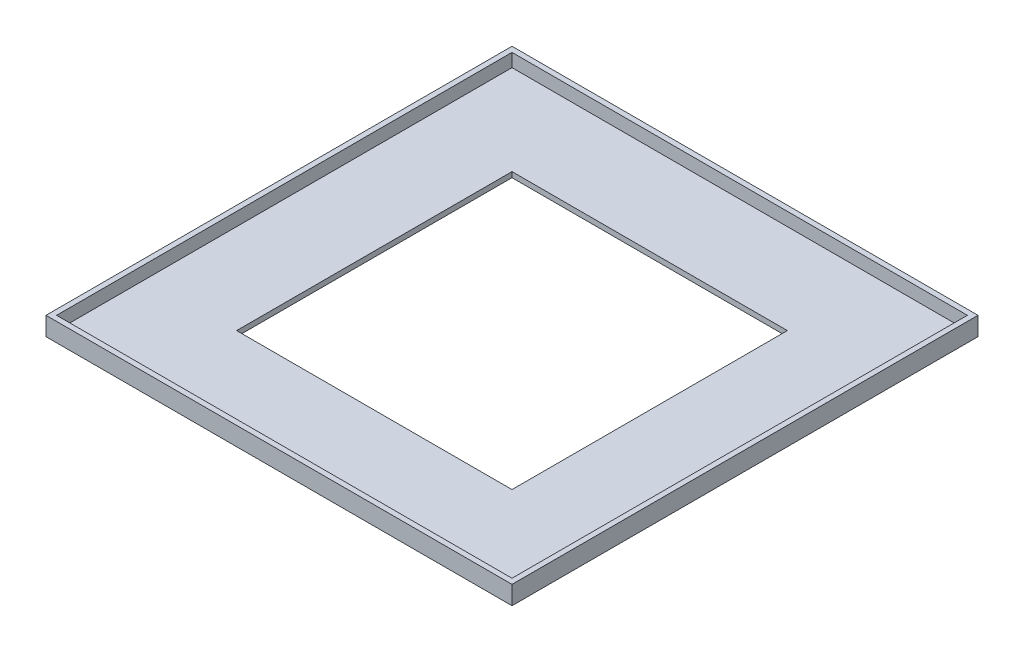
from build123d import *

# Parameters (mm, degrees)
SKETCH1_W           = 88
SKETCH1_H           = 88
BOSS_EXTRUDE1_DEPTH = 3.5
SKETCH2_W           = 86
SKETCH2_H           = 86
CUT_EXTRUDE1_DEPTH  = 2.5
SKETCH3_W           = 52
SKETCH3_H           = 52
CUT_EXTRUDE2_DEPTH  = 2


with BuildPart() as part:
    # Sketch1 → Boss-Extrude1 (new body)
    with BuildSketch(Plane(origin=(0, 0, 0), x_dir=(1, 0, 0), z_dir=(0, 1, 0))):
        Rectangle(SKETCH1_W, SKETCH1_H)
    extrude(amount=BOSS_EXTRUDE1_DEPTH)

    # Sketch2 → Cut-Extrude1 (cut)
    with BuildSketch(Plane(origin=(0, 3.5, 0), x_dir=(1, 0, 0), z_dir=(0, 1, 0))):
        Rectangle(SKETCH2_W, SKETCH2_H)
    extrude(amount=-CUT_EXTRUDE1_DEPTH, mode=Mode.SUBTRACT)

    # Sketch3 → Cut-Extrude2 (cut, through all)
    with BuildSketch(Plane(origin=(0, 1, 0), x_dir=(1, 0, 0), z_dir=(0, 1, 0))):
        Rectangle(SKETCH3_W, SKETCH3_H)
    extrude(amount=-CUT_EXTRUDE2_DEPTH, mode=Mode.SUBTRACT)


solid = part.part
